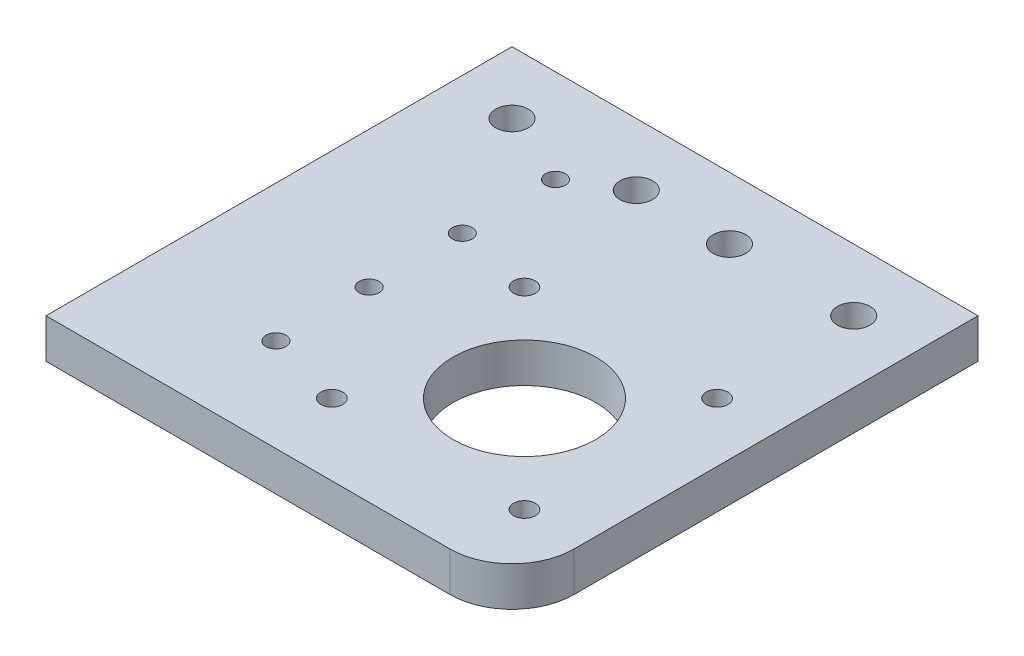
from build123d import *

# Parameters (mm, degrees)
SKETCH1_W           = 75
SKETCH1_H           = 75
SKETCH1_R           = 2.625
BOSS_EXTRUDE1_DEPTH = 6.35
FILLET1_R           = 10
SKETCH3_R           = 11.5
SKETCH3_R_2         = 1.75
CUT_EXTRUDE2_DEPTH  = 7.35
SKETCH4_R           = 1.6
CUT_EXTRUDE3_DEPTH  = 7.35


with BuildPart() as part:
    # Sketch1 → Boss-Extrude1 (new body)
    with BuildSketch(Plane(origin=(0, 0, 0), x_dir=(1, 0, 0), z_dir=(0, 1, 0))):
        with Locations((37.5, -37.5)):
            Rectangle(SKETCH1_W, SKETCH1_H)
        with Locations((10, -10)):
            Circle(SKETCH1_R, mode=Mode.SUBTRACT)
        with Locations((45, -10)):
            Circle(SKETCH1_R, mode=Mode.SUBTRACT)
        with Locations((65, -10)):
            Circle(SKETCH1_R, mode=Mode.SUBTRACT)
        with Locations((30, -10)):
            Circle(SKETCH1_R, mode=Mode.SUBTRACT)
    extrude(amount=BOSS_EXTRUDE1_DEPTH)

    # Fillet1
    fillet1_edges = [part.edges().sort_by_distance(p)[0] for p in [
        (75, 3.175, 75),
    ]]
    fillet(fillet1_edges, radius=FILLET1_R)

    # Sketch3 → Cut-Extrude2 (cut, through all)
    with BuildSketch(Plane(origin=(0, 6.35, 0), x_dir=(1, 0, 0), z_dir=(0, 1, 0))):
        with Locations((50, -48)):
            Circle(SKETCH3_R)
        with Locations((34.5, -32.5)):
            Circle(SKETCH3_R_2)
        with Locations((65.5, -32.5)):
            Circle(SKETCH3_R_2)
        with Locations((65.5, -63.5)):
            Circle(SKETCH3_R_2)
        with Locations((34.5, -63.5)):
            Circle(SKETCH3_R_2)
    extrude(amount=-CUT_EXTRUDE2_DEPTH, mode=Mode.SUBTRACT)

    # Sketch4 → Cut-Extrude3 (cut, through all)
    with BuildSketch(Plane(origin=(0, 6.35, 0), x_dir=(1, 0, 0), z_dir=(0, 1, 0))):
        with Locations((22, -15)):
            Circle(SKETCH4_R)
        with Locations((22, -30)):
            Circle(SKETCH4_R)
        with Locations((22, -45)):
            Circle(SKETCH4_R)
        with Locations((22, -60)):
            Circle(SKETCH4_R)
    extrude(amount=-CUT_EXTRUDE3_DEPTH, mode=Mode.SUBTRACT)


solid = part.part
